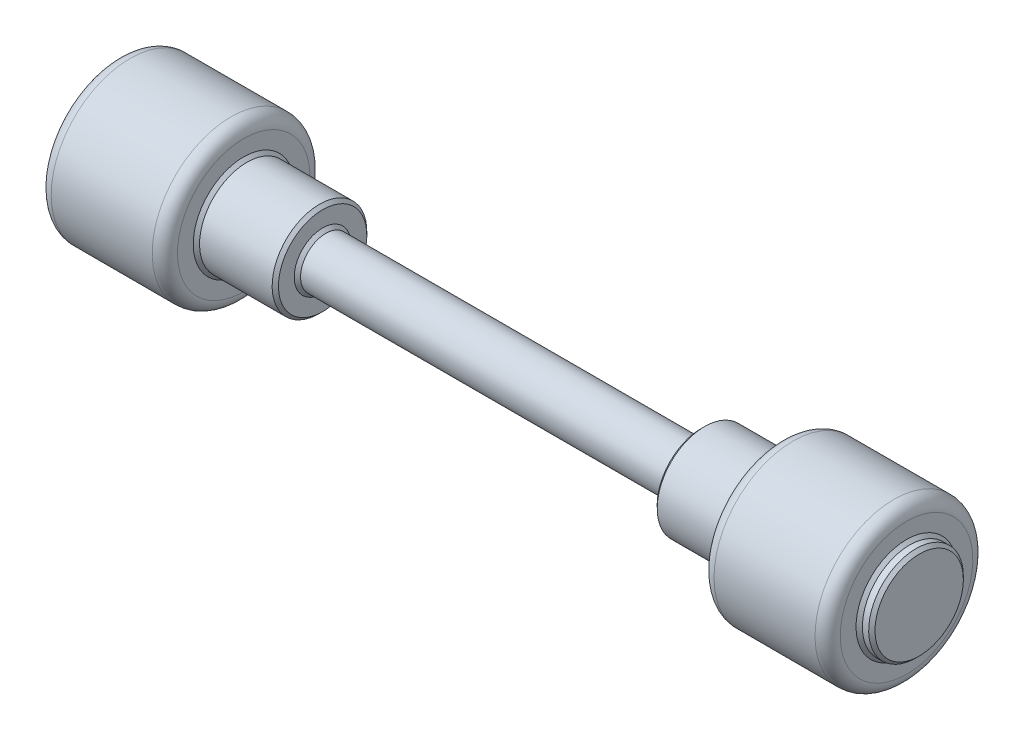
from build123d import *

# Parameters (mm, degrees)
CHAMFER1_SIZE = 12.5
FILLET1_R     = 50


with BuildPart() as part:
    # Sketch1 → Revolve1 (revolve)
    with BuildSketch(Plane.XY):
        Polygon((1612.5, 0), (-1612.5, 0), (-1612.5, 187.5), (-1562.5, 187.5), (-1562.5, 312.5), (-1062.5, 312.5), (-1062.5, 187.5), (-750, 187.5), (-750, 100), (750, 100), (750, 187.5), (1062.5, 187.5), (1062.5, 312.5), (1562.5, 312.5), (1562.5, 187.5), (1612.5, 187.5), align=None)
    revolve(axis=Axis((1612.5, 0, 0), (-1, 0, 0)))

    # Chamfer1
    chamfer1_edges = [part.edges().sort_by_distance(p)[0] for p in [
        (-1562.5, -187.5, 0),
        (-1612.5, -187.5, 0),
        (1612.5, -187.5, 0),
        (1562.5, -187.5, 0),
        (1062.5, -187.5, 0),
        (750, -187.5, 0),
        (750, -100, 0),
        (-750, -100, 0),
        (-750, -187.5, 0),
        (-1062.5, -187.5, 0),
    ]]
    chamfer(chamfer1_edges, length=CHAMFER1_SIZE)

    # Fillet1
    fillet1_edges = [part.edges().sort_by_distance(p)[0] for p in [
        (-1562.5, -312.5, 0),
        (1562.5, -312.5, 0),
        (1062.5, -312.5, 0),
        (-1062.5, -312.5, 0),
    ]]
    fillet(fillet1_edges, radius=FILLET1_R)


solid = part.part
